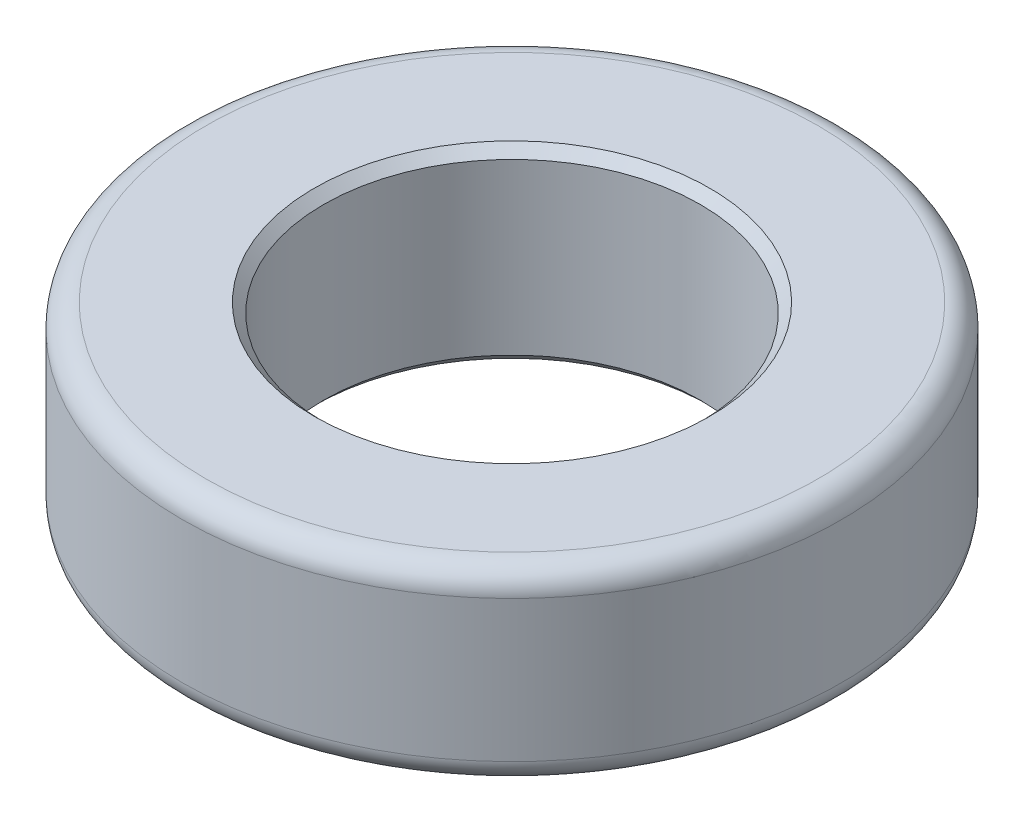
from build123d import *

# Parameters (mm, degrees)
SKETCH1_R           = 7
SKETCH1_R_2         = 4
BOSS_EXTRUDE1_DEPTH = 4
CHAMFER1_SIZE       = 0.2
FILLET1_R           = 0.5


with BuildPart() as part:
    # Sketch1 → Boss-Extrude1 (new body)
    with BuildSketch(Plane(origin=(0, 0, 0), x_dir=(1, 0, 0), z_dir=(0, 1, 0))):
        Circle(SKETCH1_R)
        Circle(SKETCH1_R_2, mode=Mode.SUBTRACT)
    extrude(amount=BOSS_EXTRUDE1_DEPTH)

    # Chamfer1
    chamfer1_edges = [part.edges().sort_by_distance(p)[0] for p in [
        (-4, 0, 0),
        (-4, 4, 0),
    ]]
    chamfer(chamfer1_edges, length=CHAMFER1_SIZE)

    # Fillet1
    fillet1_edges = [part.edges().sort_by_distance(p)[0] for p in [
        (-7, 0, 0),
        (-7, 4, 0),
    ]]
    fillet(fillet1_edges, radius=FILLET1_R)


solid = part.part
